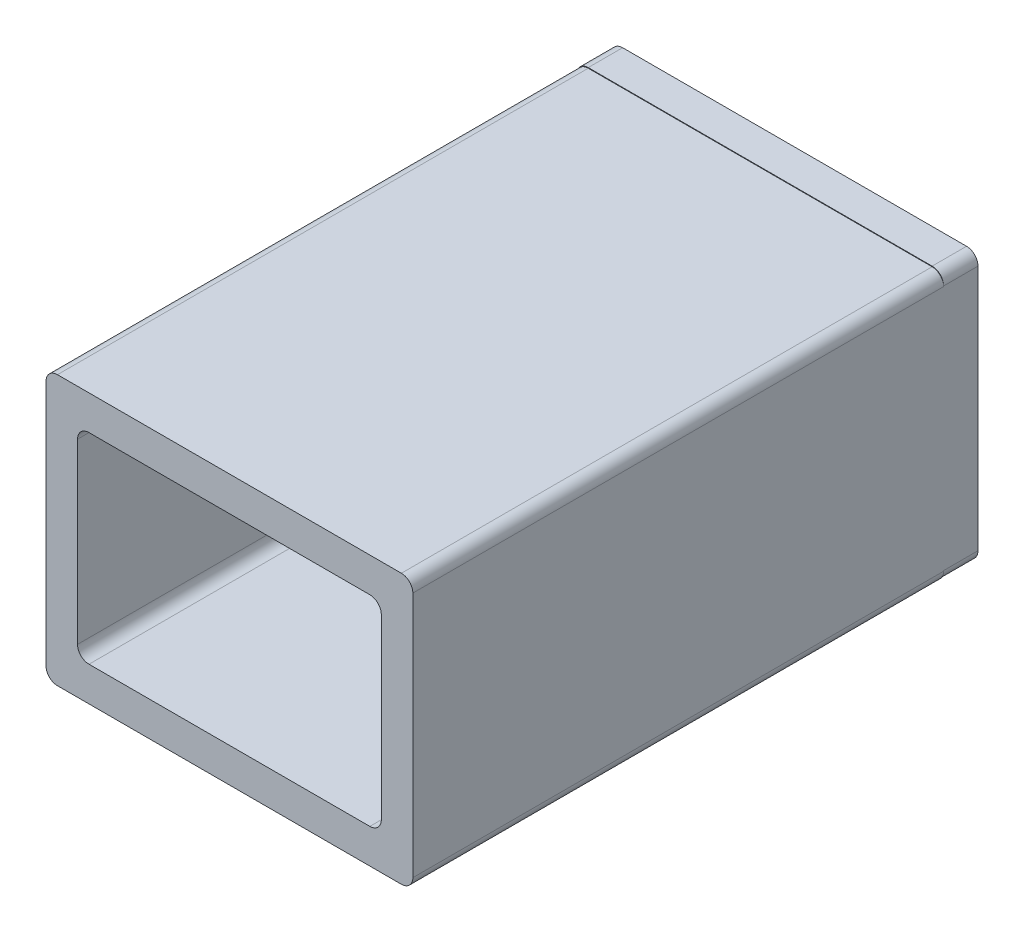
from build123d import *

# Parameters (mm, degrees)
BOSS_EXTRUDE1_DEPTH = 46.3
BOSS_EXTRUDE2_DEPTH = 3


with BuildPart() as part:
    # Sketch1 → Boss-Extrude1 (new body)
    with BuildSketch(Plane.XY):
        with BuildLine():
            Line((-15, 11.75), (15, 11.75))
            ThreePointArc((15, 11.75), (15.707106781, 11.457106781), (16, 10.75))
            Line((16, 10.75), (16, -10.75))
            ThreePointArc((16, -10.75), (15.707106781, -11.457106781), (15, -11.75))
            Line((15, -11.75), (-15, -11.75))
            ThreePointArc((-15, -11.75), (-15.707106781, -11.457106781), (-16, -10.75))
            Line((-16, -10.75), (-16, 10.75))
            ThreePointArc((-16, 10.75), (-15.707106781, 11.457106781), (-15, 11.75))
        make_face()
        with BuildLine():
            Line((-12.25, 8.75), (12.25, 8.75))
            ThreePointArc((12.25, 8.75), (12.957106781, 8.457106781), (13.25, 7.75))
            Line((13.25, 7.75), (13.25, -7.75))
            ThreePointArc((13.25, -7.75), (12.957106781, -8.457106781), (12.25, -8.75))
            Line((12.25, -8.75), (-12.25, -8.75))
            ThreePointArc((-12.25, -8.75), (-12.957106781, -8.457106781), (-13.25, -7.75))
            Line((-13.25, -7.75), (-13.25, 7.75))
            ThreePointArc((-13.25, 7.75), (-12.957106781, 8.457106781), (-12.25, 8.75))
        make_face(mode=Mode.SUBTRACT)
    extrude(amount=BOSS_EXTRUDE1_DEPTH)

    # Sketch3 → Boss-Extrude2 (add)
    with BuildSketch(Plane.XY):
        with BuildLine():
            Line((-15, 11.8), (15, 11.8))
            ThreePointArc((15, 11.8), (15.707106781, 11.507106781), (16, 10.8))
            Line((16, 10.8), (16, -10.7))
            ThreePointArc((16, -10.7), (15.707106781, -11.407106781), (15, -11.7))
            Line((15, -11.7), (-15, -11.7))
            ThreePointArc((-15, -11.7), (-15.707106781, -11.407106781), (-16, -10.7))
            Line((-16, -10.7), (-16, 10.8))
            ThreePointArc((-16, 10.8), (-15.707106781, 11.507106781), (-15, 11.8))
        make_face()
    extrude(amount=-BOSS_EXTRUDE2_DEPTH)


solid = part.part
